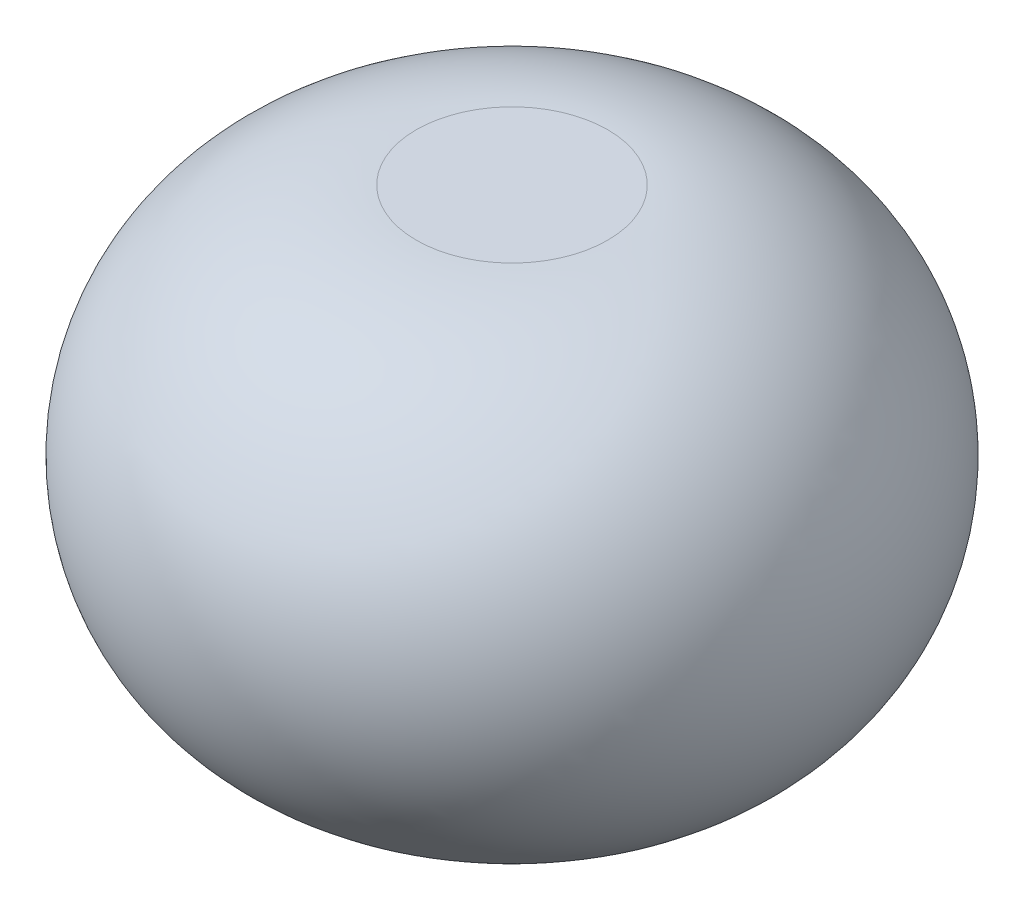
from build123d import *


with BuildPart() as part:
    # Sketch1 → Revolve1 (revolve)
    with BuildSketch(Plane.XY):
        with BuildLine():
            Line((0, 23), (9, 23))
            ThreePointArc((9, 23), (31, 1), (9, -21))
            Line((9, -21), (0, -21))
            Line((0, -21), (0, 23))
        make_face()
    revolve(axis=Axis((0, -31.03821831, 0), (0, 1, 0)))


solid = part.part
